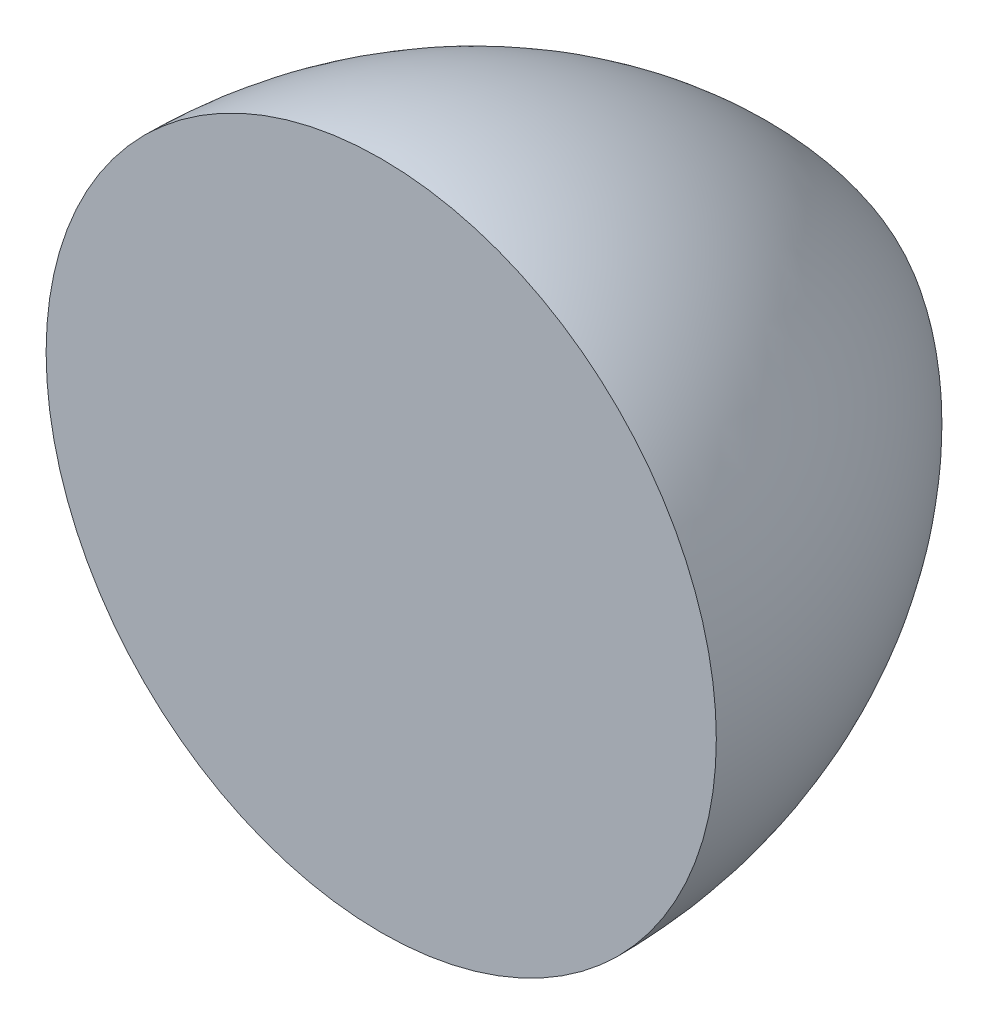
from build123d import *


with BuildPart() as part:
    # Sketch1 → Revolve2 (revolve)
    with BuildSketch(Plane(origin=(0, 0, 0), x_dir=(0, 0, -1), z_dir=(1, 0, 0))):
        with BuildLine():
            Line((0, 0), (0, 100))
            ThreePointArc((0, 100), (90.138781887, 72.70817283), (150, 0))
            Line((150, 0), (0, 0))
        make_face()
    revolve(axis=Axis((0, 0, 0), (0, 0, -1)))


solid = part.part
